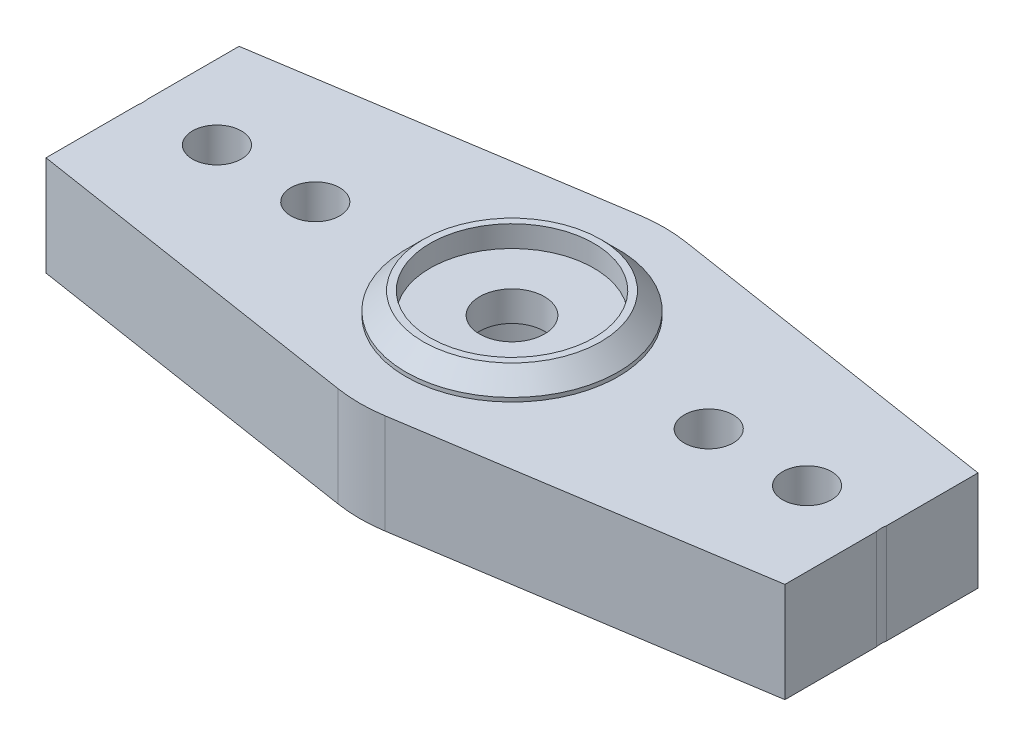
from build123d import *

# Parameters (mm, degrees)
SKETCH1_R           = 1.651
SKETCH1_R_2         = 1.2446
BOSS_EXTRUDE1_DEPTH = 5.08
SKETCH2_R           = 5.40385
SKETCH2_R_2         = 4.1656
BOSS_EXTRUDE2_DEPTH = 1.0922
CHAMFER1_SIZE       = 0.889
SKETCH4_R           = 5.4102
SKETCH4_R_2         = 4.1656
BOSS_EXTRUDE3_DEPTH = 1.4986
CHAMFER2_SIZE       = 0.254
SKETCH5_W           = 15.127715844
SKETCH5_H           = 12.166577881
CUT_EXTRUDE1_DEPTH  = 7.5786
SKETCH6_R           = 4.1656
CUT_EXTRUDE2_DEPTH  = 3.556


with BuildPart() as part:
    # Sketch1 → Boss-Extrude1 (new body)
    with BuildSketch(Plane(origin=(0, 0, 0), x_dir=(1, 0, 0), z_dir=(0, 1, 0))):
        with BuildLine():
            Line((-30.503852792, 3.086942476), (-1.192854484, 7.654613457))
            ThreePointArc((-1.192854484, 7.654613457), (0, 7.747), (1.192854484, 7.654613457))
            Line((1.192854484, 7.654613457), (30.503852792, 3.086942476))
            ThreePointArc((30.503852792, 3.086942476), (33.147, 0), (30.503852792, -3.086942476))
            Line((30.503852792, -3.086942476), (1.192854484, -7.654613457))
            ThreePointArc((1.192854484, -7.654613457), (0, -7.747), (-1.192854484, -7.654613457))
            Line((-1.192854484, -7.654613457), (-30.503852792, -3.086942476))
            ThreePointArc((-30.503852792, -3.086942476), (-33.147, 0), (-30.503852792, 3.086942476))
        make_face()
        Circle(SKETCH1_R, mode=Mode.SUBTRACT)
        with Locations((-10.0076, 0)):
            Circle(SKETCH1_R_2, mode=Mode.SUBTRACT)
        with Locations((-15.0114, 0)):
            Circle(SKETCH1_R_2, mode=Mode.SUBTRACT)
        with Locations((-20.0152, 0)):
            Circle(SKETCH1_R_2, mode=Mode.SUBTRACT)
        with Locations((-25.019, 0)):
            Circle(SKETCH1_R_2, mode=Mode.SUBTRACT)
        with Locations((-30.0228, 0)):
            Circle(SKETCH1_R_2, mode=Mode.SUBTRACT)
        with Locations((30.0228, 0)):
            Circle(SKETCH1_R_2, mode=Mode.SUBTRACT)
        with Locations((25.019, 0)):
            Circle(SKETCH1_R_2, mode=Mode.SUBTRACT)
        with Locations((20.0152, 0)):
            Circle(SKETCH1_R_2, mode=Mode.SUBTRACT)
        with Locations((15.0114, 0)):
            Circle(SKETCH1_R_2, mode=Mode.SUBTRACT)
        with Locations((10.0076, 0)):
            Circle(SKETCH1_R_2, mode=Mode.SUBTRACT)
    extrude(amount=BOSS_EXTRUDE1_DEPTH)

    # Sketch2 → Boss-Extrude2 (add)
    with BuildSketch(Plane(origin=(0, 5.08, 0), x_dir=(1, 0, 0), z_dir=(0, 1, 0))):
        Circle(SKETCH2_R)
        Circle(SKETCH2_R_2, mode=Mode.SUBTRACT)
    extrude(amount=BOSS_EXTRUDE2_DEPTH)

    # Chamfer1
    chamfer1_edges = [part.edges().sort_by_distance(p)[0] for p in [
        (-5.40385, 6.1722, 0),
    ]]
    chamfer(chamfer1_edges, length=CHAMFER1_SIZE)

    # Sketch4 → Boss-Extrude3 (add)
    with BuildSketch(Plane.XZ):
        Circle(SKETCH4_R)
        Circle(SKETCH4_R_2, mode=Mode.SUBTRACT)
    extrude(amount=BOSS_EXTRUDE3_DEPTH)

    # Chamfer2
    chamfer2_edges = [part.edges().sort_by_distance(p)[0] for p in [
        (-5.4102, -1.4986, 0),
    ]]
    chamfer(chamfer2_edges, length=CHAMFER2_SIZE)

    # Sketch5 → Cut-Extrude1 (cut, through all)
    with BuildSketch(Plane(origin=(0, 5.08, 0), x_dir=(1, 0, 0), z_dir=(0, 1, 0))):
        with Locations((-26.359857922, -0.574807794)):
            Rectangle(SKETCH5_W, SKETCH5_H)
        with Locations((26.359857922, -0.574807794)):
            Rectangle(SKETCH5_W, SKETCH5_H)
    extrude(amount=-CUT_EXTRUDE1_DEPTH, mode=Mode.SUBTRACT)

    # Sketch6 → Cut-Extrude2 (cut)
    with BuildSketch(Plane.XZ):
        Circle(SKETCH6_R)
    extrude(amount=-CUT_EXTRUDE2_DEPTH, mode=Mode.SUBTRACT)


solid = part.part
